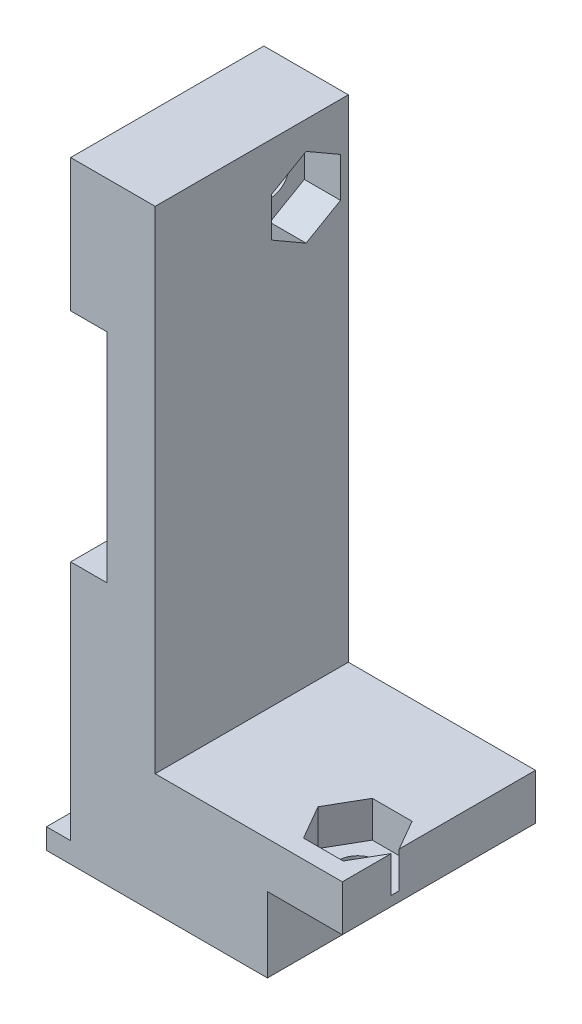
from build123d import *

# Parameters (mm, degrees)
SALIENTE_EXTRUIR1_DEPTH = 16
CORTAR_EXTRUIR1_REACH   = 18
CROQUIS2_W              = 6.2
CROQUIS2_H              = 6.2
CORTAR_EXTRUIR2_REACH   = 24.5
CROQUIS3_R              = 1.6
CORTAR_EXTRUIR3_DEPTH   = 3
CORTAR_EXTRUIR4_REACH   = 46.5
CROQUIS5_R              = 1.6
CORTAR_EXTRUIR5_DEPTH   = 3


with BuildPart() as part:
    # Croquis1 → Saliente-Extruir1 (new body)
    with BuildSketch(Plane.XY):
        Polygon((0, 0), (0, 1.7), (2, 1.7), (2, 21.7), (5, 21.7), (5, 39.7), (2, 39.7), (2, 50.7), (9, 50.7), (9, 10), (24.5, 10), (24.5, 0), align=None)
    extrude(amount=SALIENTE_EXTRUIR1_DEPTH)

    # Croquis2 → Cortar-Extruir1 (cut, up to next)
    with BuildSketch(Plane.XY.offset(16), mode=Mode.PRIVATE) as cortar_extruir1_sk1:
        with Locations((21.4, 3.1)):
            Rectangle(CROQUIS2_W, CROQUIS2_H)
    cortar_extruir1_tool1 = extrude(cortar_extruir1_sk1.sketch, amount=-CORTAR_EXTRUIR1_REACH, mode=Mode.PRIVATE) & part.part
    add(cortar_extruir1_tool1.solids().sort_by_distance((21.4, 3.1, 16))[0], mode=Mode.SUBTRACT)

    # Croquis3 → Cortar-Extruir2 (cut, up to next)
    with BuildSketch(Plane.ZY.offset(-2), mode=Mode.PRIVATE) as cortar_extruir2_sk1:
        with Locations((3.5, 45.1)):
            Circle(CROQUIS3_R)
    cortar_extruir2_tool1 = extrude(cortar_extruir2_sk1.sketch, amount=-CORTAR_EXTRUIR2_REACH, mode=Mode.PRIVATE) & part.part
    add(cortar_extruir2_tool1.solids().sort_by_distance((2, 45.1, 3.5))[0], mode=Mode.SUBTRACT)

    # Croquis4 → Cortar-Extruir3 (cut)
    with BuildSketch(Plane(origin=(9, 0, 0), x_dir=(0, 0, -1), z_dir=(1, 0, 0))):
        Polygon((-0.65, 46.745448267), (-3.5, 48.390896534), (-6.35, 46.745448267), (-6.35, 43.454551733), (-3.5, 41.809103466), (-0.65, 43.454551733), align=None)
    extrude(amount=-CORTAR_EXTRUIR3_DEPTH, mode=Mode.SUBTRACT)

    # Croquis5 → Cortar-Extruir4 (cut, up to next)
    with BuildSketch(Plane.XZ.offset(-6.2), mode=Mode.PRIVATE) as cortar_extruir4_sk1:
        with Locations((21.4, 11.62)):
            Circle(CROQUIS5_R)
    cortar_extruir4_tool1 = extrude(cortar_extruir4_sk1.sketch, amount=-CORTAR_EXTRUIR4_REACH, mode=Mode.PRIVATE) & part.part
    add(cortar_extruir4_tool1.solids().sort_by_distance((21.4, 6.2, 11.62))[0], mode=Mode.SUBTRACT)

    # Croquis6 → Cortar-Extruir5 (cut)
    with BuildSketch(Plane(origin=(0, 10, 0), x_dir=(1, 0, 0), z_dir=(0, 1, 0))):
        Polygon((19.754551733, -14.47), (23.045448267, -14.47), (24.690896534, -11.62), (23.045448267, -8.77), (19.754551733, -8.77), (18.109103466, -11.62), align=None)
    extrude(amount=-CORTAR_EXTRUIR5_DEPTH, mode=Mode.SUBTRACT)


solid = part.part
